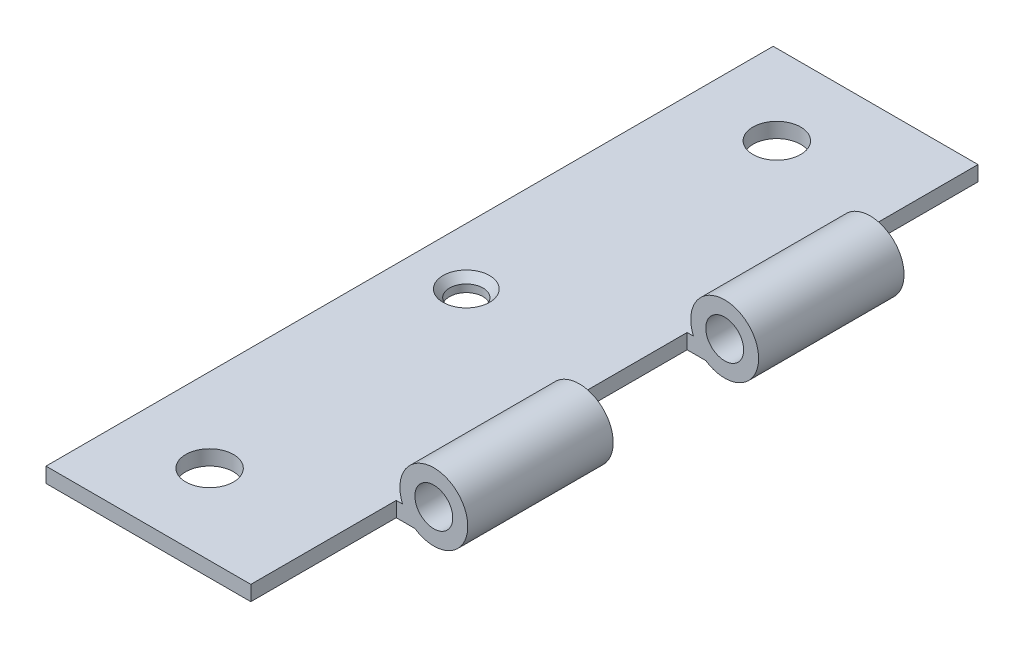
from build123d import *

# Parameters (mm, degrees)
BOSS_EXTRUDE1_DEPTH                            = 15.24
SKETCH2_W                                      = 15.24
SKETCH2_H                                      = 1.5748
BOSS_EXTRUDE2_DEPTH                            = 0.254646985
SKETCH3_W                                      = 30.48
SKETCH3_H                                      = 1.5748
BOSS_EXTRUDE3_DEPTH                            = 21.866377542
SKETCH4_W                                      = 15.24
SKETCH4_H                                      = 1.5748
CUT_EXTRUDE1_DEPTH                             = 0.403377542
BOSS_EXTRUDE4_DEPTH                            = 15.24
SKETCH6_W                                      = 21.463
SKETCH6_H                                      = 1.5748
BOSS_EXTRUDE5_DEPTH                            = 15.24
SKETCH7_W                                      = 21.463
SKETCH7_H                                      = 1.5748
BOSS_EXTRUDE6_DEPTH                            = 15.24
SKETCH8_W                                      = 1.984375
SKETCH8_H                                      = 30.480025
M3_5_CLEARANCE_HOLE2_D                         = 3.96875
M3_5_CLEARANCE_HOLE2_DEPTH                     = 60.960025
CSK_FOR_M3_FLAT_HEAD_MACHINE_SCREW1_AT_2_COUNT = 2
CSK_FOR_M3_FLAT_HEAD_MACHINE_SCREW1_AT_2_PITCH = 59.436
CSK_FOR_M3_FLAT_HEAD_MACHINE_SCREW1_AT_3_COUNT = 2
CSK_FOR_M3_FLAT_HEAD_MACHINE_SCREW1_AT_3_PITCH = 29.851441177
SKETCH14_R                                     = 2.5
CUT_EXTRUDE2_DEPTH                             = 1.5748


with BuildPart() as part:
    # Sketch1 → Boss-Extrude1 (new body)
    with BuildSketch(Plane.XY.offset(-7.62)):
        with BuildLine():
            Line((-3.278975474, -1.376029012), (-3.278975474, -2.950829012))
            Line((-3.278975474, -2.950829012), (-1.984375, -2.950829012))
            ThreePointArc((-1.984375, -2.950829012), (2.746946179, 2.258190135), (-3.278975474, -1.376029012))
        make_face()
    extrude(amount=-BOSS_EXTRUDE1_DEPTH)

    # Sketch2 → Boss-Extrude2 (add)
    with BuildSketch(Plane.ZY.offset(3.278975474)):
        with Locations((-15.24, -2.163429012)):
            Rectangle(SKETCH2_W, SKETCH2_H)
    extrude(amount=BOSS_EXTRUDE2_DEPTH)

    # Sketch3 → Boss-Extrude3 (add)
    with BuildSketch(Plane.ZY.offset(3.533622458)):
        with Locations((-7.62, -2.163429012)):
            Rectangle(SKETCH3_W, SKETCH3_H)
    extrude(amount=BOSS_EXTRUDE3_DEPTH)

    # Sketch4 → Cut-Extrude1 (cut)
    with BuildSketch(Plane(origin=(-3.533622458, 0, 0), x_dir=(0, 0, -1), z_dir=(1, 0, 0))):
        with Locations((0, -2.163429012)):
            Rectangle(SKETCH4_W, SKETCH4_H)
    extrude(amount=-CUT_EXTRUDE1_DEPTH, mode=Mode.SUBTRACT)

    # Sketch5 → Boss-Extrude4 (add)
    with BuildSketch(Plane.XY.offset(7.62)):
        with BuildLine():
            Line((-25.4, -1.376029012), (-3.278975474, -1.376029012))
            ThreePointArc((-3.278975474, -1.376029012), (2.746946179, 2.258190135), (-1.984375, -2.950829012))
            Line((-1.984375, -2.950829012), (-25.4, -2.950829012))
            Line((-25.4, -2.950829012), (-25.4, -1.376029012))
        make_face()
    extrude(amount=BOSS_EXTRUDE4_DEPTH)

    # Sketch6 → Boss-Extrude5 (add)
    with BuildSketch(Plane.XY.offset(22.86)):
        with Locations((-14.6685, -2.163429012)):
            Rectangle(SKETCH6_W, SKETCH6_H)
    extrude(amount=BOSS_EXTRUDE5_DEPTH)

    # Sketch7 → Boss-Extrude6 (add)
    with BuildSketch(Plane(origin=(0, 0, -22.86), x_dir=(-1, 0, 0), z_dir=(0, 0, -1))):
        with Locations((14.6685, -2.163429012)):
            Rectangle(SKETCH7_W, SKETCH7_H)
    extrude(amount=BOSS_EXTRUDE6_DEPTH)

    # Sketch8 → M3.5 Clearance Hole1 (revolve, cut)
    with BuildSketch(Plane(origin=(0, 0, 7.62), x_dir=(0, 1, 0), z_dir=(1, 0, 0))):
        with Locations((0.9921875, 15.2400125)):
            Rectangle(SKETCH8_W, SKETCH8_H)
    revolve(axis=Axis((0, 0, 1.27), (0, 0, 1)), mode=Mode.SUBTRACT)

    # M3.5 Clearance Hole2
    with Locations(Plane(origin=(0, 0, -22.86), x_dir=(-1, 0, 0), z_dir=(0, 0, -1))):
        with Locations((0, 0)):
            Hole(M3_5_CLEARANCE_HOLE2_D / 2, depth=M3_5_CLEARANCE_HOLE2_DEPTH)

    # Sketch12 → CSK for M3 Flat Head Machine Screw1 (revolve, cut)
    with BuildSketch(Plane(origin=(-16.637, -1.376029012, -29.718), x_dir=(0, 0, 1), z_dir=(1, 0, 0))):
        Polygon((0, 0), (0, 2.179970988), (1.7526, 2.179970988), (1.7526, 0.7874), (2.437076377, 0), align=None)
    csk_for_m3_flat_head_machine_screw1 = revolve(axis=Axis((-16.637, 4.973970988, -29.718), (0, -1, 0)), mode=Mode.SUBTRACT)

    # CSK for M3 Flat Head Machine Screw1 at 2: CSK for M3 Flat Head Machine Screw1 ×2
    with Locations(*[(0, 0, i * CSK_FOR_M3_FLAT_HEAD_MACHINE_SCREW1_AT_2_PITCH) for i in range(1, CSK_FOR_M3_FLAT_HEAD_MACHINE_SCREW1_AT_2_COUNT)]):
        add(csk_for_m3_flat_head_machine_screw1, mode=Mode.SUBTRACT)

    # CSK for M3 Flat Head Machine Screw1 at 3: CSK for M3 Flat Head Machine Screw1 ×2
    with Locations(*[Vector(-0.094447701, 0, 0.995529825) * (i * CSK_FOR_M3_FLAT_HEAD_MACHINE_SCREW1_AT_3_PITCH) for i in range(1, CSK_FOR_M3_FLAT_HEAD_MACHINE_SCREW1_AT_3_COUNT)]):
        add(csk_for_m3_flat_head_machine_screw1, mode=Mode.SUBTRACT)

    # Sketch14 → Cut-Extrude2 (cut)
    with BuildSketch(Plane(origin=(0, -1.376029012, 0), x_dir=(1, 0, 0), z_dir=(0, 1, 0))):
        with Locations((-16.637, 29.718)):
            Circle(SKETCH14_R)
        with Locations((-16.637, -29.718)):
            Circle(SKETCH14_R)
    extrude(amount=-CUT_EXTRUDE2_DEPTH, mode=Mode.SUBTRACT)


solid = part.part
